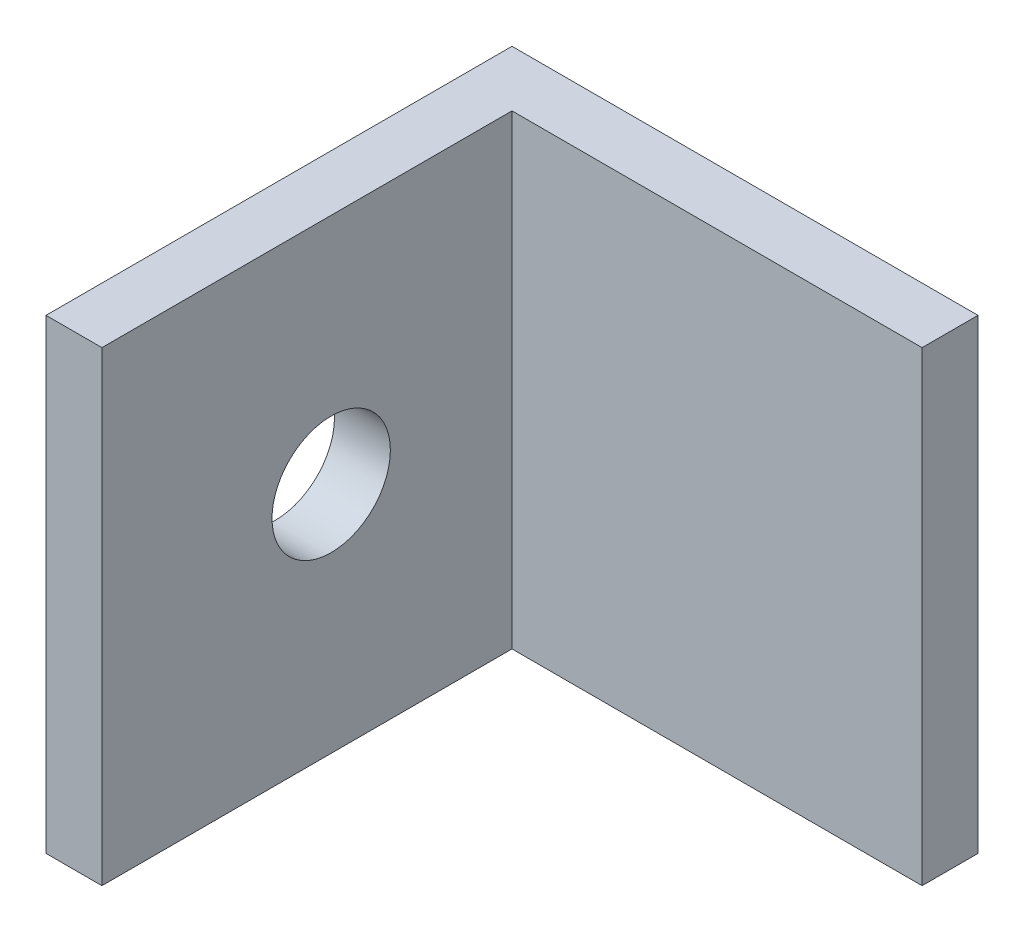
from build123d import *

# Parameters (mm, degrees)
BOSS_EXTRUDE1_DEPTH = 25
SKETCH2_R           = 3.175
CUT_EXTRUDE1_DEPTH  = 4


with BuildPart() as part:
    # Sketch1 → Boss-Extrude1 (new body)
    with BuildSketch(Plane(origin=(0, 0, 0), x_dir=(1, 0, 0), z_dir=(0, 1, 0))):
        Polygon((3, 0), (0, 0), (0, -3), (0, -25), (3, -25), (3, -3), (25, -3), (25, 0), align=None)
    extrude(amount=BOSS_EXTRUDE1_DEPTH)

    # Sketch2 → Cut-Extrude1 (cut, through all)
    with BuildSketch(Plane(origin=(3, 0, 0), x_dir=(0, 0, -1), z_dir=(1, 0, 0))):
        with Locations((-12.7, 12.5)):
            Circle(SKETCH2_R)
    extrude(amount=-CUT_EXTRUDE1_DEPTH, mode=Mode.SUBTRACT)


solid = part.part
